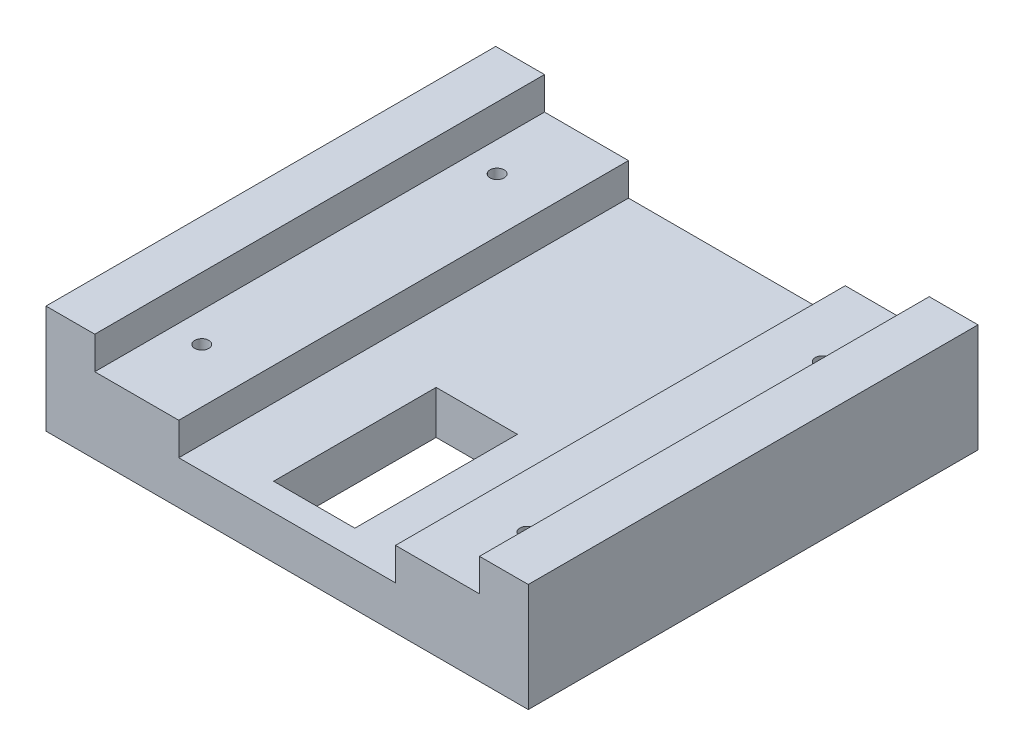
from build123d import *

# Parameters (mm, degrees)
SKETCH1_W           = 89
SKETCH1_H           = 83
SKETCH1_R           = 1.3
SKETCH1_W_2         = 15
SKETCH1_H_2         = 30
MAIN_BODY_DEPTH     = 14
SKETCH2_W           = 40
SKETCH2_H           = 83
SCREW_GROOVE_DEPTH  = 6
SKETCH4_W           = 9
SKETCH4_H           = 83
BOSS_EXTRUDE2_DEPTH = 6


with BuildPart() as part:
    # Sketch1 → Main Body (new body)
    with BuildSketch(Plane(origin=(0, 0, 0), x_dir=(1, 0, 0), z_dir=(0, 1, 0))):
        with Locations((0, 41.5)):
            Rectangle(SKETCH1_W, SKETCH1_H)
        with Locations((30, 68.75)):
            Circle(SKETCH1_R, mode=Mode.SUBTRACT)
        with Locations((-30, 68.75)):
            Circle(SKETCH1_R, mode=Mode.SUBTRACT)
        with Locations((-30, 14.25)):
            Circle(SKETCH1_R, mode=Mode.SUBTRACT)
        with Locations((30, 14.25)):
            Circle(SKETCH1_R, mode=Mode.SUBTRACT)
        with Locations((0, 20)):
            Rectangle(SKETCH1_W_2, SKETCH1_H_2, mode=Mode.SUBTRACT)
    extrude(amount=MAIN_BODY_DEPTH)

    # Sketch2 → Screw Groove (cut)
    with BuildSketch(Plane(origin=(0, 14, 0), x_dir=(1, 0, 0), z_dir=(0, 1, 0))):
        with Locations((0, 41.5)):
            Rectangle(SKETCH2_W, SKETCH2_H)
    extrude(amount=-SCREW_GROOVE_DEPTH, mode=Mode.SUBTRACT)

    # Sketch4 → Boss-Extrude2 (add)
    with BuildSketch(Plane(origin=(0, 14, 0), x_dir=(1, 0, 0), z_dir=(0, 1, 0))):
        with Locations((-40, 41.5)):
            Rectangle(SKETCH4_W, SKETCH4_H)
        with Locations((40, 41.5)):
            Rectangle(SKETCH4_W, SKETCH4_H)
    extrude(amount=BOSS_EXTRUDE2_DEPTH)


solid = part.part
